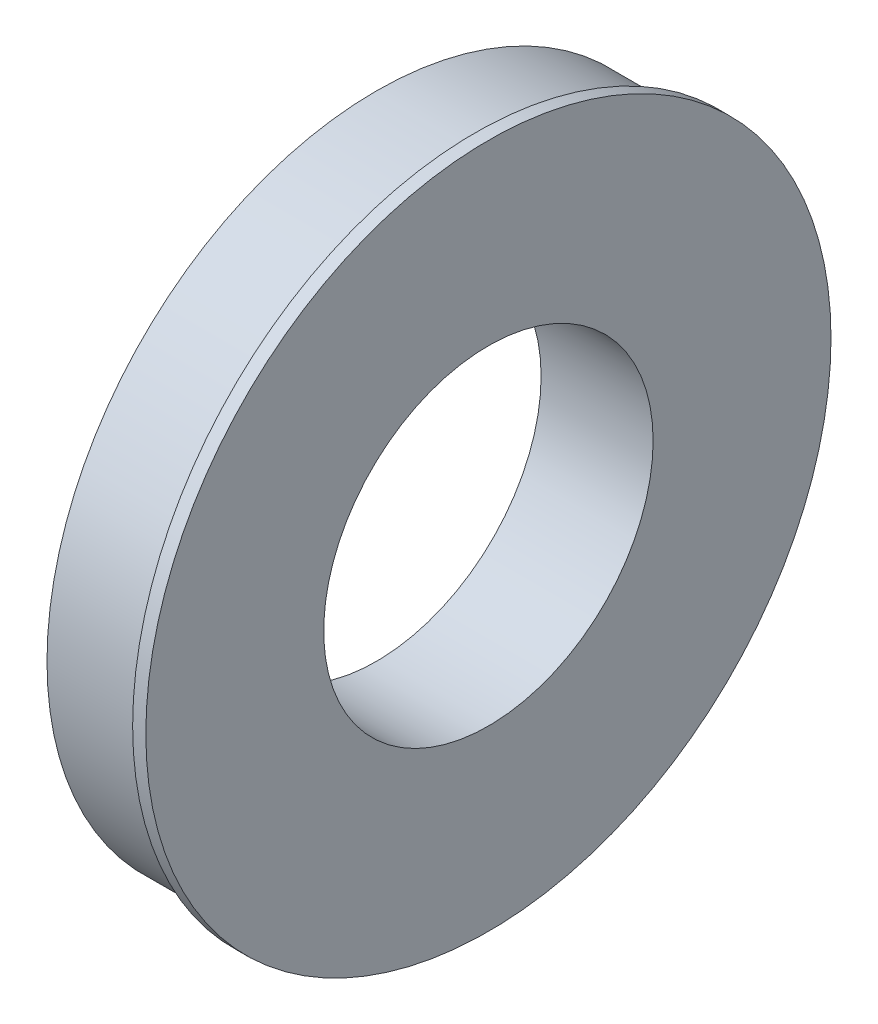
from build123d import *

# Parameters (mm, degrees)
CROQUIS1_R              = 63.5
CROQUIS1_R_2            = 31.75
SALIENTE_EXTRUIR1_DEPTH = 19.05
CROQUIS2_R              = 66.04
CROQUIS2_R_2            = 31.75
SALIENTE_EXTRUIR3_DEPTH = 2.54


with BuildPart() as part:
    # Croquis1 → Saliente-Extruir1 (new body)
    with BuildSketch(Plane(origin=(0, 0, 0), x_dir=(0, 0, -1), z_dir=(1, 0, 0))):
        Circle(CROQUIS1_R)
        Circle(CROQUIS1_R_2, mode=Mode.SUBTRACT)
    extrude(amount=SALIENTE_EXTRUIR1_DEPTH)

    # Croquis2 → Saliente-Extruir3 (add)
    with BuildSketch(Plane(origin=(19.05, 0, 0), x_dir=(0, 0, -1), z_dir=(1, 0, 0))):
        Circle(CROQUIS2_R)
        Circle(CROQUIS2_R_2, mode=Mode.SUBTRACT)
    extrude(amount=SALIENTE_EXTRUIR3_DEPTH)


solid = part.part
